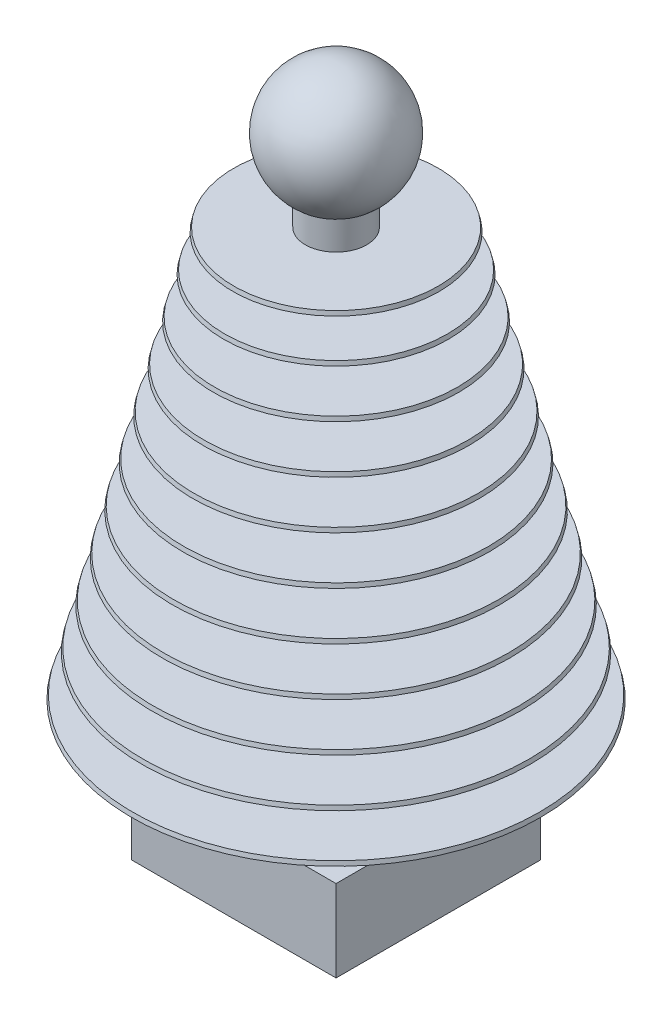
from build123d import *

# Parameters (mm, degrees)
SKETCH2_R                = 7.5
BOSS_EXTRUDE1_DEPTH      = 109
BOSS_EXTRUDE1_DEPTH_BACK = 15
SKETCH4_W                = 50
SKETCH4_H                = 50
BOSS_EXTRUDE2_DEPTH      = 20


with BuildPart() as part:
    # Sketch1 → Revolve1 (revolve)
    with BuildSketch(Plane.XY):
        Polygon((0, 50), (25, 50), (25.25, 49), (0, 49), align=None)
        Polygon((50, -50), (0, -50), (0, -49), (49.75, -49), align=None)
        Polygon((0, -39), (47.25, -39), (47.5, -40), (0, -40), align=None)
        Polygon((0, -29), (44.75, -29), (45, -30), (0, -30), align=None)
        Polygon((0, -19), (42.25, -19), (42.5, -20), (0, -20), align=None)
        Polygon((0, -9), (39.75, -9), (40, -10), (0, -10), align=None)
        Polygon((0, 1), (37.25, 1), (37.5, 0), (0, 0), align=None)
        Polygon((0, 11), (34.75, 11), (35, 10), (0, 10), align=None)
        Polygon((0, 21), (32.25, 21), (32.5, 20), (0, 20), align=None)
        Polygon((0, 31), (29.75, 31), (30, 30), (0, 30), align=None)
        Polygon((0, 41), (27.25, 41), (27.5, 40), (0, 40), align=None)
    revolve(axis=Axis((0, -50, 0), (0, 1, 0)))

    # Sketch2 → Boss-Extrude1 (add, two sides)
    with BuildSketch(Plane(origin=(0, -49, 0), x_dir=(1, 0, 0), z_dir=(0, 1, 0))) as boss_extrude1_sk:
        Circle(SKETCH2_R)
    extrude(amount=BOSS_EXTRUDE1_DEPTH)
    extrude(boss_extrude1_sk.sketch, amount=-BOSS_EXTRUDE1_DEPTH_BACK)

    # Sketch3 → Revolve2 (revolve)
    with BuildSketch(Plane.XY):
        with BuildLine():
            Line((0, 85), (0, 55))
            ThreePointArc((0, 55), (15, 70), (0, 85))
        make_face()
    revolve(axis=Axis((0, -55, 0), (0, 1, 0)))

    # Sketch4 → Boss-Extrude2 (add)
    with BuildSketch(Plane.XZ.offset(64)):
        Rectangle(SKETCH4_W, SKETCH4_H)
    extrude(amount=BOSS_EXTRUDE2_DEPTH)


solid = part.part
